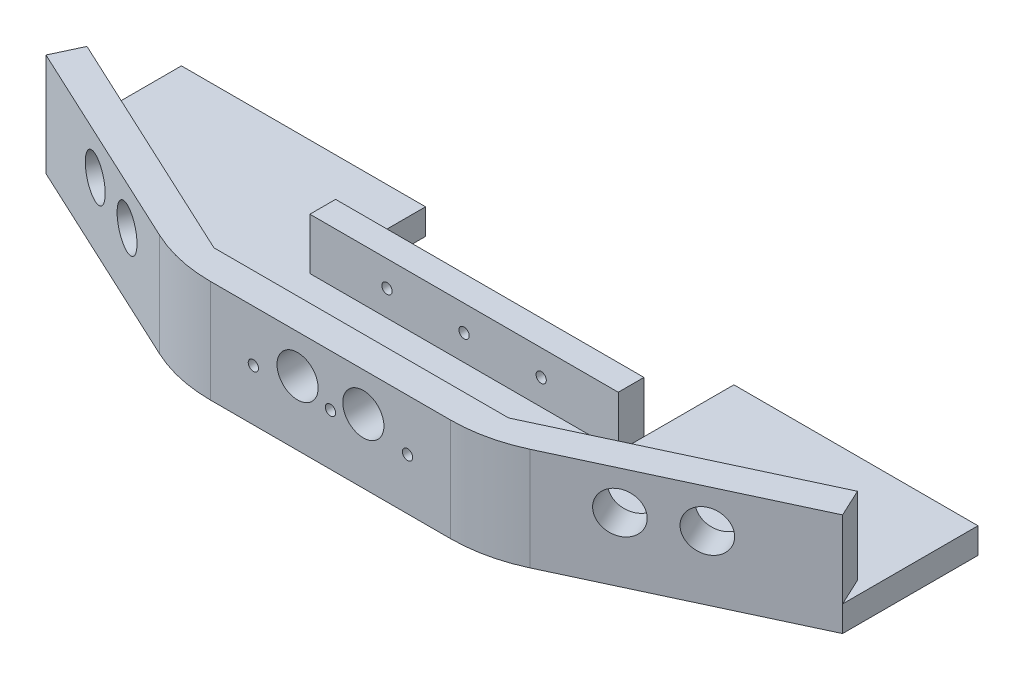
from build123d import *

# Parameters (mm, degrees)
EXTRUDE_THIN1_DEPTH = 30
SKETCH2_R           = 8
CUT_EXTRUDE1_DEPTH  = 141.868386798
SKETCH3_R           = 8
CUT_EXTRUDE2_DEPTH  = 56.174920969
BOSS_EXTRUDE1_DEPTH = 10
SKETCH7_W           = 120
SKETCH7_H           = 30
BOSS_EXTRUDE2_DEPTH = 10
SKETCH8_R           = 2
CUT_EXTRUDE3_DEPTH  = 63
FILLET1_R           = 60
SKETCH9_W           = 95
SKETCH9_H           = 52.700772475
BOSS_EXTRUDE3_DEPTH = 10
SKETCH10_W          = 11
SKETCH10_H          = 4
SKETCH10_H_2        = 5
CUT_EXTRUDE4_DEPTH  = 4.5
SKETCH13_W          = 11
SKETCH13_H          = 5
SKETCH13_H_2        = 4
CUT_EXTRUDE5_DEPTH  = 4


with BuildPart() as part:
    # Sketch1 → Extrude-Thin1 (new body)
    with BuildSketch(Plane(origin=(0, 0, 0), x_dir=(1, 0, 0), z_dir=(0, 1, 0))):
        Polygon((-155, 44.299227525), (-60, 0), (60, 0), (155, 44.299227525), (149.928580859, 55.174920969), (57.339664048, 12), (-57.339664048, 12), (-149.928580859, 55.174920969), align=None)
    extrude(amount=EXTRUDE_THIN1_DEPTH)

    # Sketch2 → Cut-Extrude1 (cut, through all)
    with BuildSketch(Plane(origin=(10.716371709, 0, 22.981333294), x_dir=(0.906307787, 0, -0.422618262), z_dir=(0.422618262, 0, 0.906307787))):
        with Locations((93.988918373, 15)):
            Circle(SKETCH2_R)
        with Locations((119.588918373, 15)):
            Circle(SKETCH2_R)
    cut_extrude1 = extrude(amount=-CUT_EXTRUDE1_DEPTH, mode=Mode.SUBTRACT)

    # Mirror1: Cut-Extrude1 across plane
    add(cut_extrude1.mirror(Plane(origin=(0, 0, 0), x_dir=(0, 0, 1), z_dir=(1, 0, 0))), mode=Mode.SUBTRACT)

    # Sketch3 → Cut-Extrude2 (cut, through all)
    with BuildSketch(Plane.XY):
        with Locations((12.8, 15)):
            Circle(SKETCH3_R)
        with Locations((-12.8, 15)):
            Circle(SKETCH3_R)
    extrude(amount=-CUT_EXTRUDE2_DEPTH, mode=Mode.SUBTRACT)

    # Sketch5 → Boss-Extrude1 (add)
    with BuildSketch(Plane.XZ):
        Polygon((66.80863999, -55.174920969), (149.928580859, -55.174920969), (57.339664048, -12), (-57.339664048, -12), (-149.928580859, -55.174920969), (-66.80863999, -55.174920969), (-60, -52), (60, -52), align=None)
        Polygon((-155, -44.299227525), (-149.928580859, -55.174920969), (-57.339664048, -12), (57.339664048, -12), (149.928580859, -55.174920969), (155, -44.299227525), (60, 0), (-60, 0), align=None)
    extrude(amount=BOSS_EXTRUDE1_DEPTH)

    # Sketch7 → Boss-Extrude2 (add)
    with BuildSketch(Plane(origin=(0, 0, -52), x_dir=(-1, 0, 0), z_dir=(0, 0, -1))):
        with Locations((0, 5)):
            Rectangle(SKETCH7_W, SKETCH7_H)
    extrude(amount=BOSS_EXTRUDE2_DEPTH)

    # Sketch8 → Cut-Extrude3 (cut, through all)
    with BuildSketch(Plane(origin=(0, 0, -62), x_dir=(-1, 0, 0), z_dir=(0, 0, -1))):
        with Locations((0, 10)):
            Circle(SKETCH8_R)
        with Locations((-30, 10)):
            Circle(SKETCH8_R)
        with Locations((30, 10)):
            Circle(SKETCH8_R)
    extrude(amount=-CUT_EXTRUDE3_DEPTH, mode=Mode.SUBTRACT)

    # Fillet1
    fillet1_edges = [part.edges().sort_by_distance(p)[0] for p in [
        (60, 10, 0),
        (-60, 10, 0),
    ]]
    fillet(fillet1_edges, radius=FILLET1_R)

    # Sketch9 → Boss-Extrude3 (add)
    with BuildSketch(Plane(origin=(0, 0, 0), x_dir=(1, 0, 0), z_dir=(0, 1, 0))):
        with Locations((107.5, 70.649613762)):
            Rectangle(SKETCH9_W, SKETCH9_H)
    boss_extrude3 = extrude(amount=-BOSS_EXTRUDE3_DEPTH)

    # Mirror2: Boss-Extrude3 across plane
    add(boss_extrude3.mirror(Plane(origin=(0, 0, 0), x_dir=(0, 0, 1), z_dir=(1, 0, 0))))

    # Sketch10 → Cut-Extrude4 (cut)
    with BuildSketch(Plane(origin=(5.644952569, 0, 12.105639849), x_dir=(-0.906307787, 0, 0.422618262), z_dir=(-0.422618262, 0, -0.906307787))):
        with Locations((-106.788918373, 23.3)):
            Rectangle(SKETCH10_W, SKETCH10_H)
        with Locations((-106.788918373, 7.2)):
            Rectangle(SKETCH10_W, SKETCH10_H_2)
    cut_extrude4 = extrude(amount=-CUT_EXTRUDE4_DEPTH, mode=Mode.SUBTRACT)

    # Mirror3: Cut-Extrude4 across plane
    add(cut_extrude4.mirror(Plane(origin=(0, 0, 0), x_dir=(0, 0, 1), z_dir=(1, 0, 0))), mode=Mode.SUBTRACT)

    # Sketch13 → Cut-Extrude5 (cut)
    with BuildSketch(Plane(origin=(0, 0, -12), x_dir=(-1, 0, 0), z_dir=(0, 0, -1))):
        with Locations((0, 7.2)):
            Rectangle(SKETCH13_W, SKETCH13_H)
        with Locations((0, 23.3)):
            Rectangle(SKETCH13_W, SKETCH13_H_2)
    extrude(amount=-CUT_EXTRUDE5_DEPTH, mode=Mode.SUBTRACT)


solid = part.part
